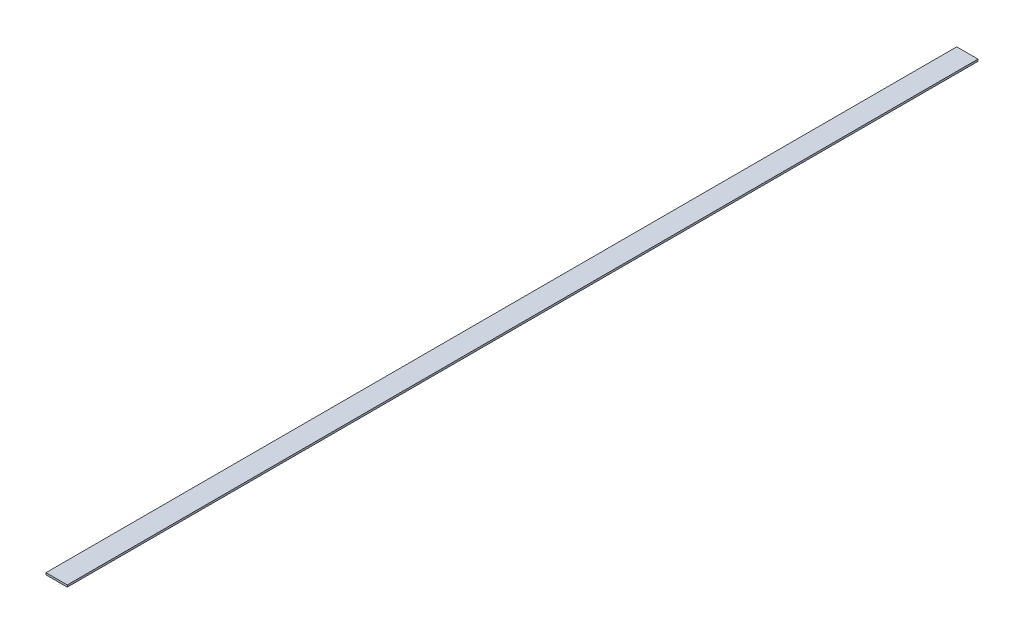
from build123d import *

# Parameters (mm, degrees)
SKETCH1_W           = 21.6
SKETCH1_H           = 2
BOSS_EXTRUDE1_DEPTH = 925


with BuildPart() as part:
    # Sketch1 → Boss-Extrude1 (new body)
    with BuildSketch(Plane.XY):
        with Locations((10.8, 1)):
            Rectangle(SKETCH1_W, SKETCH1_H)
    extrude(amount=BOSS_EXTRUDE1_DEPTH)


solid = part.part
